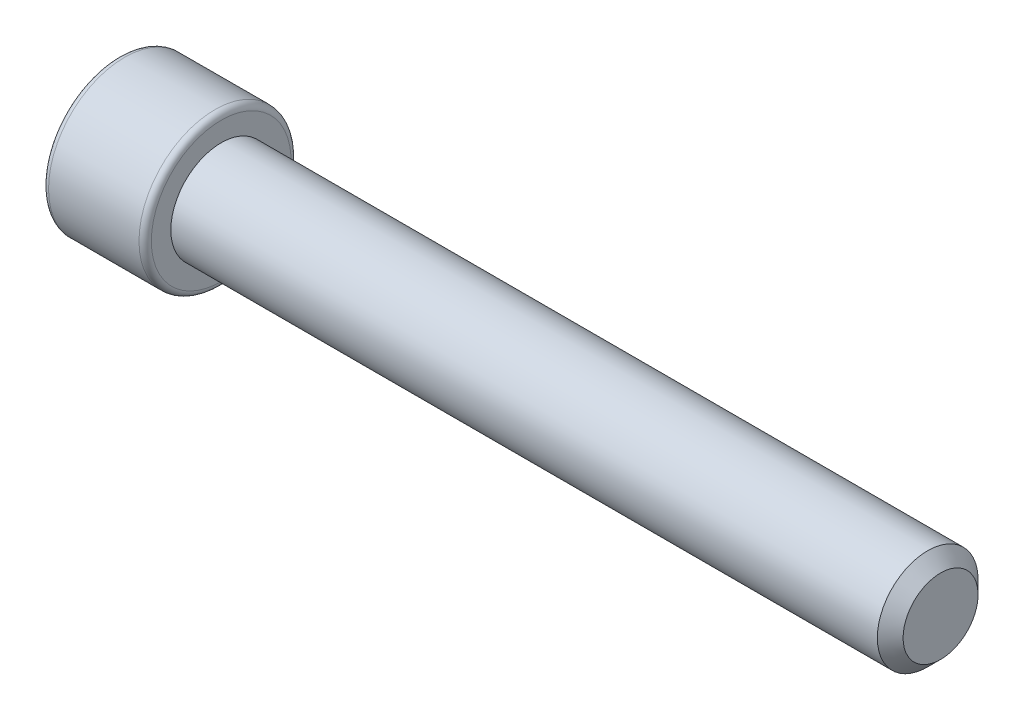
from build123d import *

# Parameters (mm, degrees)
EXTRUDE1_DEPTH = 3.81
FILLET1_R      = 0.381
CHAMFER1_SIZE  = 0.79502


with BuildPart() as part:
    # Sketch1 → Revolve1 (revolve)
    with BuildSketch(Plane.XY):
        Polygon((25.4, 0), (25.4, 3.1115), (-19.05, 3.1115), (-19.05, 4.699), (-25.4, 4.699), (-25.4, 0), align=None)
    revolve(axis=Axis((-24.504761338, 0, 0), (1, 0, 0)))

    # Sketch2 → Extrude1 (cut)
    with BuildSketch(Plane.ZY.offset(25.4)):
        Polygon((0, 2.749630657), (-2.38125, 1.374815329), (-2.38125, -1.374815329), (0, -2.749630657), (2.38125, -1.374815329), (2.38125, 1.374815329), align=None)
    extrude(amount=-EXTRUDE1_DEPTH, mode=Mode.SUBTRACT)

    # Fillet1
    fillet1_edges = [part.edges().sort_by_distance(p)[0] for p in [
        (-25.4, -4.699, 0),
        (-19.05, -4.699, 0),
    ]]
    fillet(fillet1_edges, radius=FILLET1_R)

    # Chamfer1
    chamfer1_edges = [part.edges().sort_by_distance(p)[0] for p in [
        (25.4, -3.1115, 0),
    ]]
    chamfer(chamfer1_edges, length=CHAMFER1_SIZE)


solid = part.part
